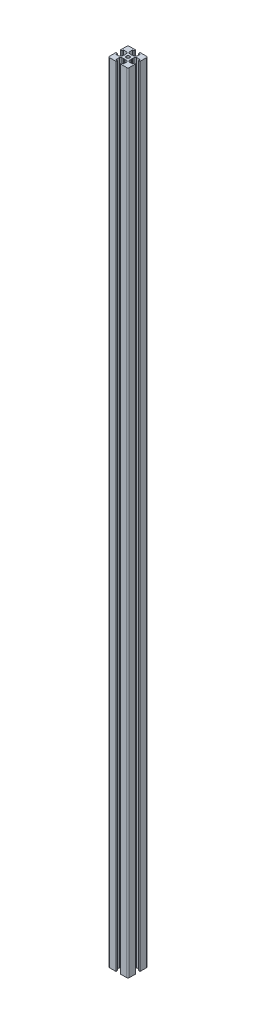
from build123d import *

# Parameters (mm, degrees)
SKETCH1_R           = 1.25
BOSS_EXTRUDE1_DEPTH = 600


with BuildPart() as part:
    # Sketch1 → Boss-Extrude1 (new body)
    with BuildSketch(Plane(origin=(0, 0, 0), x_dir=(1, 0, 0), z_dir=(0, 1, 0))):
        with BuildLine():
            Line((6.5, -7.5), (1.7, -7.5))
            Line((1.7, -7.5), (1.7, -6.4))
            Line((1.7, -6.4), (2.85, -6.4))
            Line((2.85, -6.4), (2.85, -3.8))
            Line((2.85, -3.8), (1.85, -2.8))
            Line((1.85, -2.8), (0.519615242, -2.8))
            Line((0.519615242, -2.8), (0, -2.5))
            Line((0, -2.5), (-0.519615242, -2.8))
            Line((-0.519615242, -2.8), (-1.85, -2.8))
            Line((-1.85, -2.8), (-2.85, -3.8))
            Line((-2.85, -3.8), (-2.85, -6.4))
            Line((-2.85, -6.4), (-1.7, -6.4))
            Line((-1.7, -6.4), (-1.7, -7.5))
            Line((-1.7, -7.5), (-6.5, -7.5))
            ThreePointArc((-6.5, -7.5), (-7.207106781, -7.207106781), (-7.5, -6.5))
            Line((-7.5, -6.5), (-7.5, -1.7))
            Line((-7.5, -1.7), (-6.4, -1.7))
            Line((-6.4, -1.7), (-6.4, -2.85))
            Line((-6.4, -2.85), (-3.8, -2.85))
            Line((-3.8, -2.85), (-2.8, -1.85))
            Line((-2.8, -1.85), (-2.8, -0.519615242))
            Line((-2.8, -0.519615242), (-2.5, 0))
            Line((-2.5, 0), (-2.8, 0.519615242))
            Line((-2.8, 0.519615242), (-2.8, 1.85))
            Line((-2.8, 1.85), (-3.8, 2.85))
            Line((-3.8, 2.85), (-6.4, 2.85))
            Line((-6.4, 2.85), (-6.4, 1.7))
            Line((-6.4, 1.7), (-7.5, 1.7))
            Line((-7.5, 1.7), (-7.5, 6.5))
            ThreePointArc((-7.5, 6.5), (-7.207106781, 7.207106781), (-6.5, 7.5))
            Line((-6.5, 7.5), (-1.7, 7.5))
            Line((-1.7, 7.5), (-1.7, 6.4))
            Line((-1.7, 6.4), (-2.85, 6.4))
            Line((-2.85, 6.4), (-2.85, 3.8))
            Line((-2.85, 3.8), (-1.85, 2.8))
            Line((-1.85, 2.8), (-0.519615242, 2.8))
            Line((-0.519615242, 2.8), (0, 2.5))
            Line((0, 2.5), (0.519615242, 2.8))
            Line((0.519615242, 2.8), (1.85, 2.8))
            Line((1.85, 2.8), (2.85, 3.8))
            Line((2.85, 3.8), (2.85, 6.4))
            Line((2.85, 6.4), (1.7, 6.4))
            Line((1.7, 6.4), (1.7, 7.5))
            Line((1.7, 7.5), (6.5, 7.5))
            ThreePointArc((6.5, 7.5), (7.207106781, 7.207106781), (7.5, 6.5))
            Line((7.5, 6.5), (7.5, 1.7))
            Line((7.5, 1.7), (6.4, 1.7))
            Line((6.4, 1.7), (6.4, 2.85))
            Line((6.4, 2.85), (3.8, 2.85))
            Line((3.8, 2.85), (2.8, 1.85))
            Line((2.8, 1.85), (2.8, 0.519615242))
            Line((2.8, 0.519615242), (2.5, 0))
            Line((2.5, 0), (2.8, -0.519615242))
            Line((2.8, -0.519615242), (2.8, -1.85))
            Line((2.8, -1.85), (3.8, -2.85))
            Line((3.8, -2.85), (6.4, -2.85))
            Line((6.4, -2.85), (6.4, -1.7))
            Line((6.4, -1.7), (7.5, -1.7))
            Line((7.5, -1.7), (7.5, -6.5))
            ThreePointArc((7.5, -6.5), (7.207106781, -7.207106781), (6.5, -7.5))
        make_face()
        Circle(SKETCH1_R, mode=Mode.SUBTRACT)
    extrude(amount=BOSS_EXTRUDE1_DEPTH)


solid = part.part
